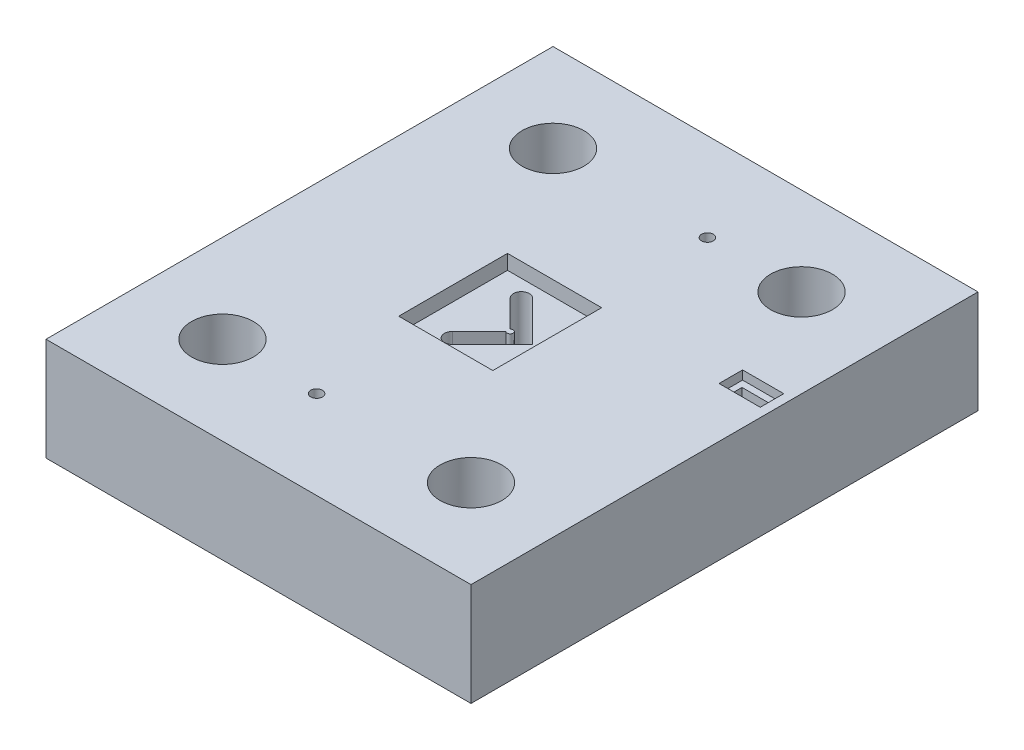
from build123d import *

# Parameters (mm, degrees)
SKETCH1_W           = 144.5
SKETCH1_H           = 172.38
BOSS_EXTRUDE1_DEPTH = 35
CUT_EXTRUDE1_REACH  = 37
SKETCH6_R           = 10.5
SKETCH6_R_2         = 1.99
SKETCH7_W           = 32
SKETCH7_H           = 37
CUT_EXTRUDE2_DEPTH  = 5
SKETCH8_W           = 14
SKETCH8_H           = 8
CUT_EXTRUDE3_DEPTH  = 3
SKETCH9_R           = 15.25
SKETCH9_R_2         = 16
CUT_EXTRUDE4_DEPTH  = 20


with BuildPart() as part:
    # Sketch1 → Boss-Extrude1 (new body)
    with BuildSketch(Plane(origin=(0, 0, 0), x_dir=(1, 0, 0), z_dir=(0, 1, 0))):
        Rectangle(SKETCH1_W, SKETCH1_H)
    extrude(amount=BOSS_EXTRUDE1_DEPTH)

    # Sketch6 → Cut-Extrude1 (cut, up to next)
    with BuildSketch(Plane(origin=(0, 35, 0), x_dir=(1, 0, 0), z_dir=(0, 1, 0)), mode=Mode.PRIVATE) as cut_extrude1_sk1:
        with Locations((42.25, -56.19)):
            Circle(SKETCH6_R)
    cut_extrude1_tool1 = extrude(cut_extrude1_sk1.sketch, amount=-CUT_EXTRUDE1_REACH, mode=Mode.PRIVATE) & part.part
    add(cut_extrude1_tool1.solids().sort_by_distance((42.25, 35, 56.19))[0], mode=Mode.SUBTRACT)
    # Sketch6 → Cut-Extrude1 (cut, up to next)
    with BuildSketch(Plane(origin=(0, 35, 0), x_dir=(1, 0, 0), z_dir=(0, 1, 0)), mode=Mode.PRIVATE) as cut_extrude1_sk2:
        with Locations((-10.25, -56.19)):
            Circle(SKETCH6_R_2)
    cut_extrude1_tool2 = extrude(cut_extrude1_sk2.sketch, amount=-CUT_EXTRUDE1_REACH, mode=Mode.PRIVATE) & part.part
    add(cut_extrude1_tool2.solids().sort_by_distance((-10.25, 35, 56.19))[0], mode=Mode.SUBTRACT)
    # Sketch6 → Cut-Extrude1 (cut, up to next)
    with BuildSketch(Plane(origin=(0, 35, 0), x_dir=(1, 0, 0), z_dir=(0, 1, 0)), mode=Mode.PRIVATE) as cut_extrude1_sk3:
        with Locations((-42.25, -56.19)):
            Circle(SKETCH6_R)
    cut_extrude1_tool3 = extrude(cut_extrude1_sk3.sketch, amount=-CUT_EXTRUDE1_REACH, mode=Mode.PRIVATE) & part.part
    add(cut_extrude1_tool3.solids().sort_by_distance((-42.25, 35, 56.19))[0], mode=Mode.SUBTRACT)
    # Sketch6 → Cut-Extrude1 (cut, up to next)
    with BuildSketch(Plane(origin=(0, 35, 0), x_dir=(1, 0, 0), z_dir=(0, 1, 0)), mode=Mode.PRIVATE) as cut_extrude1_sk4:
        with Locations((42.25, 56.19)):
            Circle(SKETCH6_R)
    cut_extrude1_tool4 = extrude(cut_extrude1_sk4.sketch, amount=-CUT_EXTRUDE1_REACH, mode=Mode.PRIVATE) & part.part
    add(cut_extrude1_tool4.solids().sort_by_distance((42.25, 35, -56.19))[0], mode=Mode.SUBTRACT)
    # Sketch6 → Cut-Extrude1 (cut, up to next)
    with BuildSketch(Plane(origin=(0, 35, 0), x_dir=(1, 0, 0), z_dir=(0, 1, 0)), mode=Mode.PRIVATE) as cut_extrude1_sk5:
        with Locations((10.25, 56.19)):
            Circle(SKETCH6_R_2)
    cut_extrude1_tool5 = extrude(cut_extrude1_sk5.sketch, amount=-CUT_EXTRUDE1_REACH, mode=Mode.PRIVATE) & part.part
    add(cut_extrude1_tool5.solids().sort_by_distance((10.25, 35, -56.19))[0], mode=Mode.SUBTRACT)
    # Sketch6 → Cut-Extrude1 (cut, up to next)
    with BuildSketch(Plane(origin=(0, 35, 0), x_dir=(1, 0, 0), z_dir=(0, 1, 0)), mode=Mode.PRIVATE) as cut_extrude1_sk6:
        with Locations((-42.25, 56.19)):
            Circle(SKETCH6_R)
    cut_extrude1_tool6 = extrude(cut_extrude1_sk6.sketch, amount=-CUT_EXTRUDE1_REACH, mode=Mode.PRIVATE) & part.part
    add(cut_extrude1_tool6.solids().sort_by_distance((-42.25, 35, -56.19))[0], mode=Mode.SUBTRACT)
    # Sketch6 → Cut-Extrude1 (cut, up to next)
    with BuildSketch(Plane(origin=(0, 35, 0), x_dir=(1, 0, 0), z_dir=(0, 1, 0)), mode=Mode.PRIVATE) as cut_extrude1_sk7:
        with BuildLine():
            Line((-10.455537495, 9.828784258), (-1.333860018, 0.707106781))
            ThreePointArc((-1.333860018, 0.707106781), (0.373246763, 0), (-1.333860018, -0.707106781))
            Line((-1.333860018, -0.707106781), (-10.455537495, -9.828784258))
            ThreePointArc((-10.455537495, -9.828784258), (-10.455537495, -13.647160877), (-6.637160877, -13.647160877))
            Line((-6.637160877, -13.647160877), (7.01, 0))
            Line((7.01, 0), (-6.637160877, 13.647160877))
            ThreePointArc((-6.637160877, 13.647160877), (-10.455537495, 13.647160877), (-10.455537495, 9.828784258))
        make_face()
    cut_extrude1_tool7 = extrude(cut_extrude1_sk7.sketch, amount=-CUT_EXTRUDE1_REACH, mode=Mode.PRIVATE) & part.part
    add(cut_extrude1_tool7.solids().sort_by_distance((-0.05515, 35, 6.582011))[0], mode=Mode.SUBTRACT)
    # Sketch6 → Cut-Extrude1 (cut, up to next)
    with BuildSketch(Plane(origin=(0, 35, 0), x_dir=(1, 0, 0), z_dir=(0, 1, 0)), mode=Mode.PRIVATE) as cut_extrude1_sk8:
        Polygon((67.25, 20.94), (67.25, 17.44), (65.25, 17.44), (65.25, 17.94), (59.25, 17.94), (59.25, 17.44), (57.25, 17.44), (57.25, 17.94), (57.25, 20.94), align=None)
    cut_extrude1_tool8 = extrude(cut_extrude1_sk8.sketch, amount=-CUT_EXTRUDE1_REACH, mode=Mode.PRIVATE) & part.part
    add(cut_extrude1_tool8.solids().sort_by_distance((62.25, 35, -19.330625))[0], mode=Mode.SUBTRACT)

    # Sketch7 → Cut-Extrude2 (cut)
    with BuildSketch(Plane(origin=(0, 35, 0), x_dir=(1, 0, 0), z_dir=(0, 1, 0))):
        with Locations((-3.07777663, -0.946773822)):
            Rectangle(SKETCH7_W, SKETCH7_H)
    extrude(amount=-CUT_EXTRUDE2_DEPTH, mode=Mode.SUBTRACT)

    # Sketch8 → Cut-Extrude3 (cut)
    with BuildSketch(Plane(origin=(0, 35, 0), x_dir=(1, 0, 0), z_dir=(0, 1, 0))):
        with Locations((62.2, 19.2)):
            Rectangle(SKETCH8_W, SKETCH8_H)
    extrude(amount=-CUT_EXTRUDE3_DEPTH, mode=Mode.SUBTRACT)

    # Sketch9 → Cut-Extrude4 (cut)
    with BuildSketch(Plane.XZ):
        with Locations((42.25, -56.19)):
            Circle(SKETCH9_R)
        with Locations((-150, -137.51)):
            Circle(SKETCH9_R_2)
        with Locations((42.25, 56.19)):
            Circle(SKETCH9_R)
        with Locations((-42.25, 56.19)):
            Circle(SKETCH9_R)
    extrude(amount=-CUT_EXTRUDE4_DEPTH, mode=Mode.SUBTRACT)


solid = part.part
